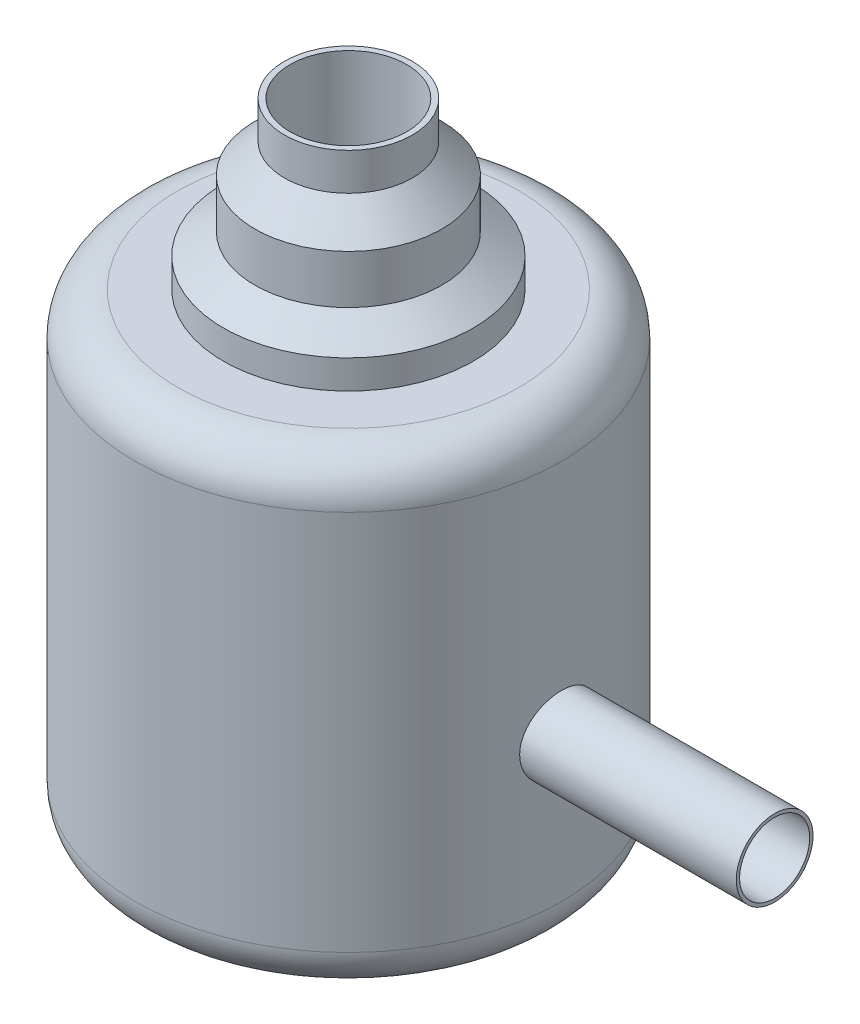
from build123d import *

# Parameters (mm, degrees)
SKETCH2_R           = 2.5
BOSS_EXTRUDE1_DEPTH = 5
SKETCH4_R           = 0.684081367
CUT_EXTRUDE1_DEPTH  = 5
FILLET2_R           = 0.5
SKETCH5_R           = 0.45
BOSS_EXTRUDE2_DEPTH = 5
SKETCH6_R           = 0.411041126
CUT_EXTRUDE2_DEPTH  = 4


with BuildPart() as part:
    # Sketch2 → Boss-Extrude1 (new body)
    with BuildSketch(Plane(origin=(0, 0, 0), x_dir=(1, 0, 0), z_dir=(0, 1, 0))):
        Circle(SKETCH2_R)
    extrude(amount=BOSS_EXTRUDE1_DEPTH)

    # Sketch3 → Revolve2 (revolve)
    with BuildSketch(Plane.XY):
        Polygon((0, 7.411705002), (-0.75, 7.411705002), (-0.75, 6.975061564), (-1.095892568, 6.629168996), (-1.095892568, 6.058427362), (-1.465907088, 5.809167185), (-1.465907088, 5.471459847), (-2.5, 5.471459847), (-2.5, 5), (0, 5), align=None)
    revolve(axis=Axis((0, 0, 0), (0, 1, 0)))

    # Sketch4 → Cut-Extrude1 (cut)
    with BuildSketch(Plane(origin=(0, 7.411705002, 0), x_dir=(1, 0, 0), z_dir=(0, 1, 0))):
        Circle(SKETCH4_R)
    extrude(amount=-CUT_EXTRUDE1_DEPTH, mode=Mode.SUBTRACT)

    # Fillet2
    fillet2_edges = [part.edges().sort_by_distance(p)[0] for p in [
        (-2.5, 0, 0),
        (2.5, 5.471459847, 0),
    ]]
    fillet(fillet2_edges, radius=FILLET2_R)

    # Sketch5 → Boss-Extrude2 (add)
    with BuildSketch(Plane(origin=(0, 0, 0), x_dir=(0, 0, -1), z_dir=(1, 0, 0))):
        with Locations((0, 2.194655863)):
            Circle(SKETCH5_R)
    extrude(amount=BOSS_EXTRUDE2_DEPTH)

    # Sketch6 → Cut-Extrude2 (cut)
    with BuildSketch(Plane(origin=(5, 0, 0), x_dir=(0, 0, -1), z_dir=(1, 0, 0))):
        with Locations((0, 2.194655863)):
            Circle(SKETCH6_R)
    extrude(amount=-CUT_EXTRUDE2_DEPTH, mode=Mode.SUBTRACT)


solid = part.part
